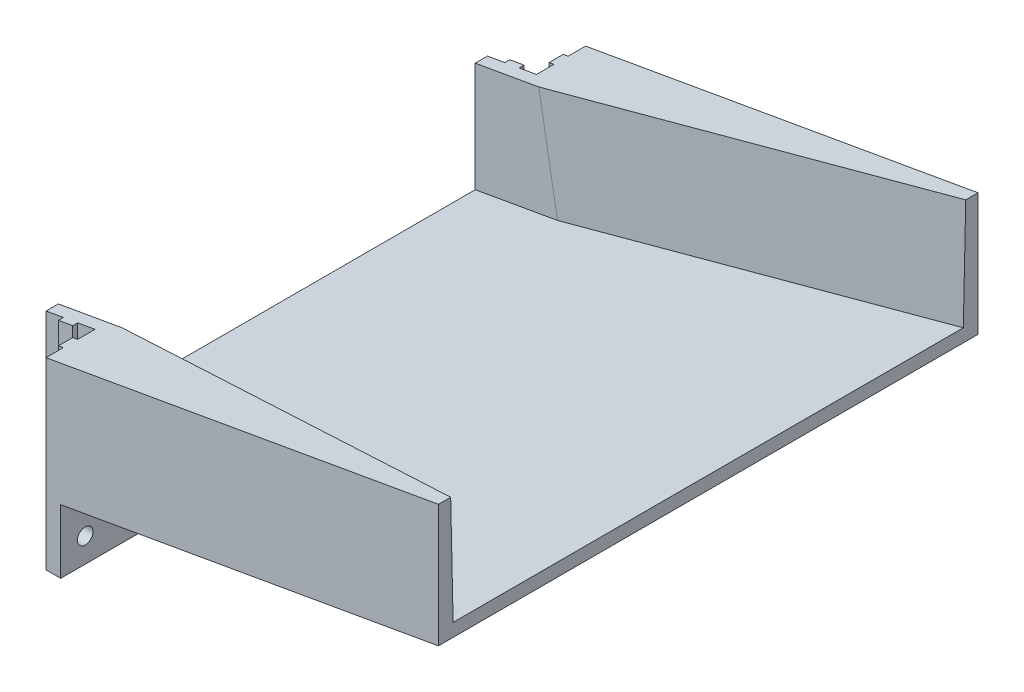
from build123d import *

# Parameters (mm, degrees)
MAIN_DEPTH              = 55
FIXING_DEPTH            = 52.577177515
ESQUISSE4_R             = 1.6
ENL_V_MAT_EXTRU_6_DEPTH = 14
CENTRAL_HOLE_DEPTH      = 22


with BuildPart() as part:
    # Esquisse1 → Main (new body, symmetric)
    with BuildSketch(Plane.XY):
        Polygon((0, 0), (13, 0), (13, 13), (90, 26.577177515), (90, 51.577177515), (0, 35.707749251), align=None)
    extrude(amount=MAIN_DEPTH, both=True)

    # Esquisse3 → Fixing (cut, through all)
    with BuildSketch(Plane(origin=(-3.294458096, 0, 0), x_dir=(1, 0, 0), z_dir=(0, 1, 0))):
        Polygon((3.294458096, 45), (6.844458096, 45), (6.844458096, 46), (9.744458096, 46), (9.744458096, 45), (13.294458096, 45), (13.294458096, 48.55), (12.294458096, 48.55), (12.294458096, 51.45), (13.294458096, 51.45), (13.294458096, 55), (3.294458096, 55), align=None)
    fixing = extrude(amount=FIXING_DEPTH, mode=Mode.SUBTRACT)

    # Esquisse4 → Enlèv. mat.-Extru.6 (cut, through all)
    with BuildSketch(Plane(origin=(13, 0, 0), x_dir=(0, 0, -1), z_dir=(1, 0, 0))):
        with Locations((-50, 5)):
            Circle(ESQUISSE4_R)
    enl_v_mat_extru_6 = extrude(amount=-ENL_V_MAT_EXTRU_6_DEPTH, mode=Mode.SUBTRACT)

    # Symétrie1: Fixing, Enlèv. mat.-Extru.6 across plane
    add(fixing.mirror(Plane.XY), mode=Mode.SUBTRACT)
    add(enl_v_mat_extru_6.mirror(Plane.XY), mode=Mode.SUBTRACT)

    # Esquisse2 → Central Hole (cut)
    with BuildSketch(Plane(origin=(-6.106384758, 34.631028863, 0), x_dir=(0.984807753, 0.173648178, 0), z_dir=(-0.173648178, 0.984807753, 0))):
        Polygon((97.588980656, 52.5), (97.588980656, -52.5), (19.354851705, -42.5), (-3.799414414, -42.5), (-3.799414414, 42.5), (19.354851705, 42.5), align=None)
    extrude(amount=-CENTRAL_HOLE_DEPTH, mode=Mode.SUBTRACT)


solid = part.part
